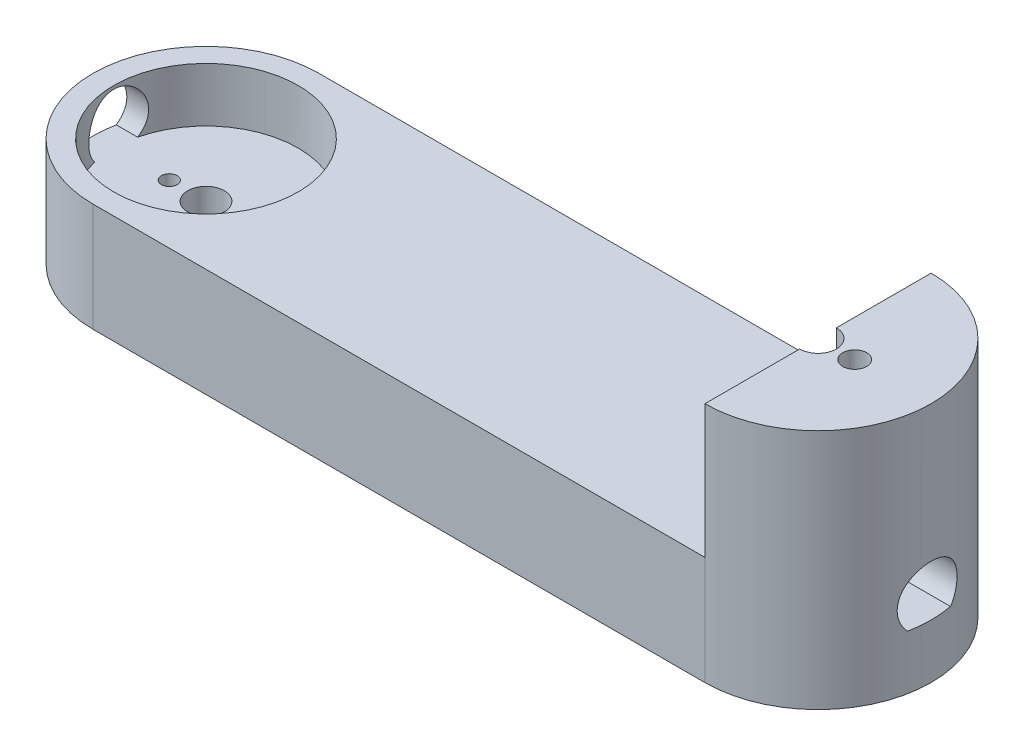
from build123d import *

# Parameters (mm, degrees)
SKETCH1_R               = 3.5
SKETCH1_R_2             = 1.498001977
BOSS_EXTRUDE1_DEPTH     = 20.7
SKETCH2_R               = 17.607245412
CUT_EXTRUDE1_DEPTH      = 10.349992
CUT_EXTRUDE2_DEPTH      = 81
CUT_EXTRUDE2_DEPTH_BACK = 81
SKETCH4_R               = 1.498001977
BOSS_EXTRUDE2_DEPTH     = 25.4
CUT_EXTRUDE3_DEPTH      = 8.89
CUT_EXTRUDE4_DEPTH      = 46.1
SKETCH7_R               = 2.286
CUT_EXTRUDE5_DEPTH      = 35.749992


with BuildPart() as part:
    # Sketch1 → Boss-Extrude1 (new body)
    with BuildSketch(Plane(origin=(0, 0, 0), x_dir=(1, 0, 0), z_dir=(0, 1, 0))):
        with BuildLine():
            Line((-58.41, 21.59), (58.41, 21.59))
            ThreePointArc((58.41, 21.59), (80, 0), (58.41, -21.59))
            Line((58.41, -21.59), (-58.41, -21.59))
            ThreePointArc((-58.41, -21.59), (-80, 0), (-58.41, 21.59))
        make_face()
        with Locations((-58.41, 0)):
            Circle(SKETCH1_R, mode=Mode.SUBTRACT)
        with Locations((-51.41, 0)):
            Circle(SKETCH1_R_2, mode=Mode.SUBTRACT)
        with Locations((-65.41, 0)):
            Circle(SKETCH1_R_2, mode=Mode.SUBTRACT)
        with Locations((51.41, 0)):
            Circle(SKETCH1_R_2, mode=Mode.SUBTRACT)
        with Locations((65.41, 0)):
            Circle(SKETCH1_R_2, mode=Mode.SUBTRACT)
        with Locations((58.41, 0)):
            Circle(SKETCH1_R, mode=Mode.SUBTRACT)
    extrude(amount=BOSS_EXTRUDE1_DEPTH)

    # Sketch2 → Cut-Extrude1 (cut)
    with BuildSketch(Plane(origin=(0, 20.7, 0), x_dir=(1, 0, 0), z_dir=(0, 1, 0))):
        with Locations((-58.41, 0)):
            Circle(SKETCH2_R)
    extrude(amount=-CUT_EXTRUDE1_DEPTH, mode=Mode.SUBTRACT)

    # Sketch3 → Cut-Extrude2 (cut, two sides)
    with BuildSketch(Plane(origin=(0, 0, 0), x_dir=(0, 0, -1), z_dir=(1, 0, 0))) as cut_extrude2_sk:
        with BuildLine():
            Line((4.081824225, 10.350008), (-4.081824225, 10.350008))
            ThreePointArc((-4.081824225, 10.350008), (0, 20.065), (4.081824225, 10.350008))
        make_face()
    extrude(amount=CUT_EXTRUDE2_DEPTH, mode=Mode.SUBTRACT)
    extrude(cut_extrude2_sk.sketch, amount=-CUT_EXTRUDE2_DEPTH_BACK, mode=Mode.SUBTRACT)

    # Sketch4 → Boss-Extrude2 (add)
    with BuildSketch(Plane(origin=(0, 20.7, 0), x_dir=(1, 0, 0), z_dir=(0, 1, 0))):
        with BuildLine():
            Line((58.41, -21.59), (58.41, 21.59))
            ThreePointArc((58.41, 21.59), (80, 0), (58.41, -21.59))
        make_face()
        with Locations((65.41, 0)):
            Circle(SKETCH4_R, mode=Mode.SUBTRACT)
    extrude(amount=BOSS_EXTRUDE2_DEPTH)

    # Sketch5 → Cut-Extrude3 (cut)
    with BuildSketch(Plane.ZY.offset(-58.41)):
        with BuildLine():
            Line((0.9525, 22.652744662), (-0.9525, 22.652744662))
            Line((-0.9525, 22.652744662), (-0.9525, 23.922744662))
            ThreePointArc((-0.9525, 23.922744662), (0, 42.925), (0.9525, 23.922744662))
            Line((0.9525, 23.922744662), (0.9525, 22.652744662))
        make_face()
    extrude(amount=-CUT_EXTRUDE3_DEPTH, mode=Mode.SUBTRACT)

    # Sketch6 → Cut-Extrude4 (cut)
    with BuildSketch(Plane(origin=(0, 46.1, 0), x_dir=(1, 0, 0), z_dir=(0, 1, 0))):
        with BuildLine():
            Line((58.41, -3.5), (58.41, 3.5))
            ThreePointArc((58.41, 3.5), (54.91, 0), (58.41, -3.5))
        make_face()
        with BuildLine():
            ThreePointArc((58.41, -3.5), (61.91, 0), (58.41, 3.5))
            Line((58.41, 3.5), (58.41, -3.5))
        make_face()
    extrude(amount=-CUT_EXTRUDE4_DEPTH, mode=Mode.SUBTRACT)

    # Sketch7 → Cut-Extrude5 (cut)
    with BuildSketch(Plane(origin=(0, 46.1, 0), x_dir=(1, 0, 0), z_dir=(0, 1, 0))):
        with Locations((65.41, 0)):
            Circle(SKETCH7_R)
    extrude(amount=-CUT_EXTRUDE5_DEPTH, mode=Mode.SUBTRACT)


solid = part.part
